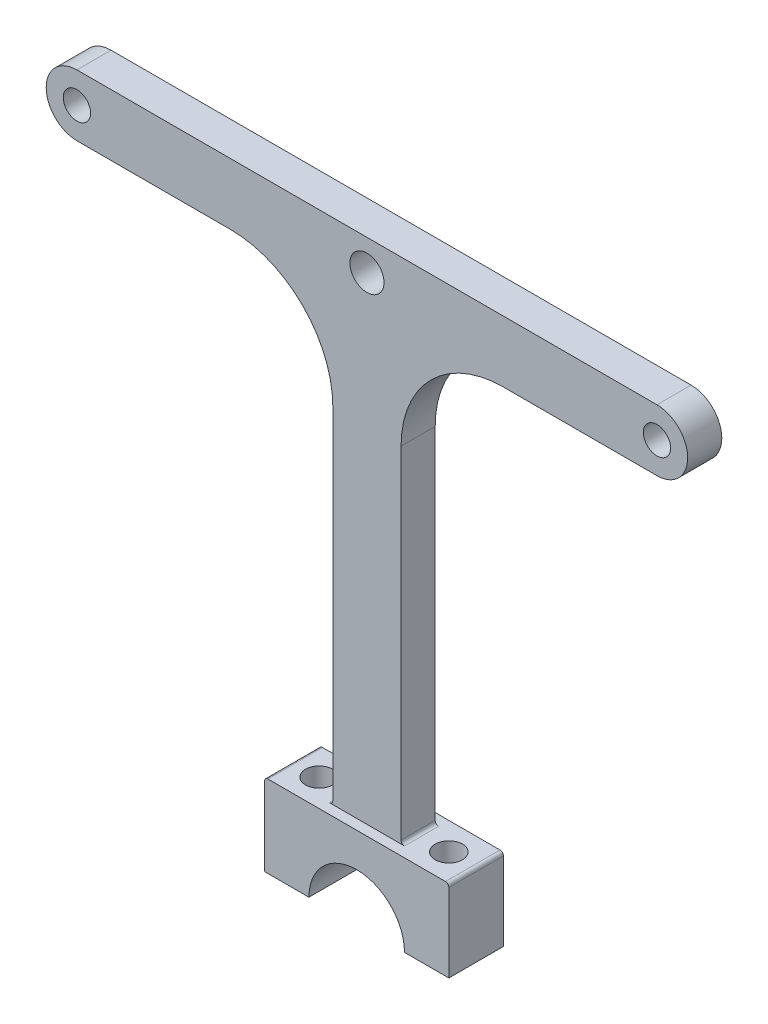
from build123d import *

# Parameters (mm, degrees)
SKETCH1_R                = 2.5
SKETCH1_R_2              = 2
BOSS_EXTRUDE1_DEPTH      = 5
BOSS_EXTRUDE2_DEPTH      = 6.5
BOSS_EXTRUDE2_DEPTH_BACK = 1.5
SKETCH2_R                = 2
CUT_EXTRUDE1_DEPTH       = 100
FILLET1_R                = 0.5


with BuildPart() as part:
    # Sketch1 → Boss-Extrude1 (new body)
    with BuildSketch(Plane.XY):
        with BuildLine():
            Line((7, 0), (13.5, 0))
            Line((13.5, 0), (13.5, 12))
            Line((13.5, 12), (5, 12))
            Line((5, 12), (5, 62.5))
            ThreePointArc((5, 62.5), (9.393398312, 73.106601748), (20.000000086, 77.5))
            Line((20.000000086, 77.5), (42.5, 77.5))
            ThreePointArc((42.5, 77.5), (47, 82), (42.5, 86.5))
            Line((42.5, 86.5), (-42.5, 86.5))
            ThreePointArc((-42.5, 86.5), (-47, 82), (-42.5, 77.5))
            Line((-42.5, 77.5), (-20, 77.5))
            ThreePointArc((-20, 77.5), (-9.393398282, 73.106601718), (-5, 62.5))
            Line((-5, 62.5), (-5, 12))
            Line((-5, 12), (-13.5, 12))
            Line((-13.5, 12), (-13.5, 0))
            Line((-13.5, 0), (-7, 0))
            ThreePointArc((-7, 0), (0, 7), (7, 0))
        make_face()
        with Locations((0, 82)):
            Circle(SKETCH1_R, mode=Mode.SUBTRACT)
        with Locations((42.5, 82)):
            Circle(SKETCH1_R_2, mode=Mode.SUBTRACT)
        with Locations((-42.5, 82)):
            Circle(SKETCH1_R_2, mode=Mode.SUBTRACT)
    extrude(amount=BOSS_EXTRUDE1_DEPTH)

    # Sketch1_3 → Boss-Extrude2 (add, two sides: drawn at the far end of the back side and taken through both)
    with BuildSketch(Plane.XY.offset(-BOSS_EXTRUDE2_DEPTH_BACK)):
        with BuildLine():
            Line((7, 0), (13.5, 0))
            Line((13.5, 0), (13.5, 12))
            Line((13.5, 12), (-13.5, 12))
            Line((-13.5, 12), (-13.5, 0))
            Line((-13.5, 0), (-7, 0))
            ThreePointArc((-7, 0), (0, 7), (7, 0))
        make_face()
    extrude(amount=BOSS_EXTRUDE2_DEPTH + BOSS_EXTRUDE2_DEPTH_BACK)

    # Sketch2 → Cut-Extrude1 (cut)
    with BuildSketch(Plane(origin=(0, 12, 0), x_dir=(1, 0, 0), z_dir=(0, 1, 0))):
        with Locations((9.5, -2.5)):
            Circle(SKETCH2_R)
        with Locations((-9.5, -2.5)):
            Circle(SKETCH2_R)
    extrude(amount=-CUT_EXTRUDE1_DEPTH, mode=Mode.SUBTRACT)

    # Fillet1
    fillet1_edges = [part.edges().sort_by_distance(p)[0] for p in [
        (-13.5, 12, 2.5),
        (-5, 12, 2.5),
        (13.5, 12, 2.5),
        (5, 12, 2.5),
    ]]
    fillet(fillet1_edges, radius=FILLET1_R)


solid = part.part
